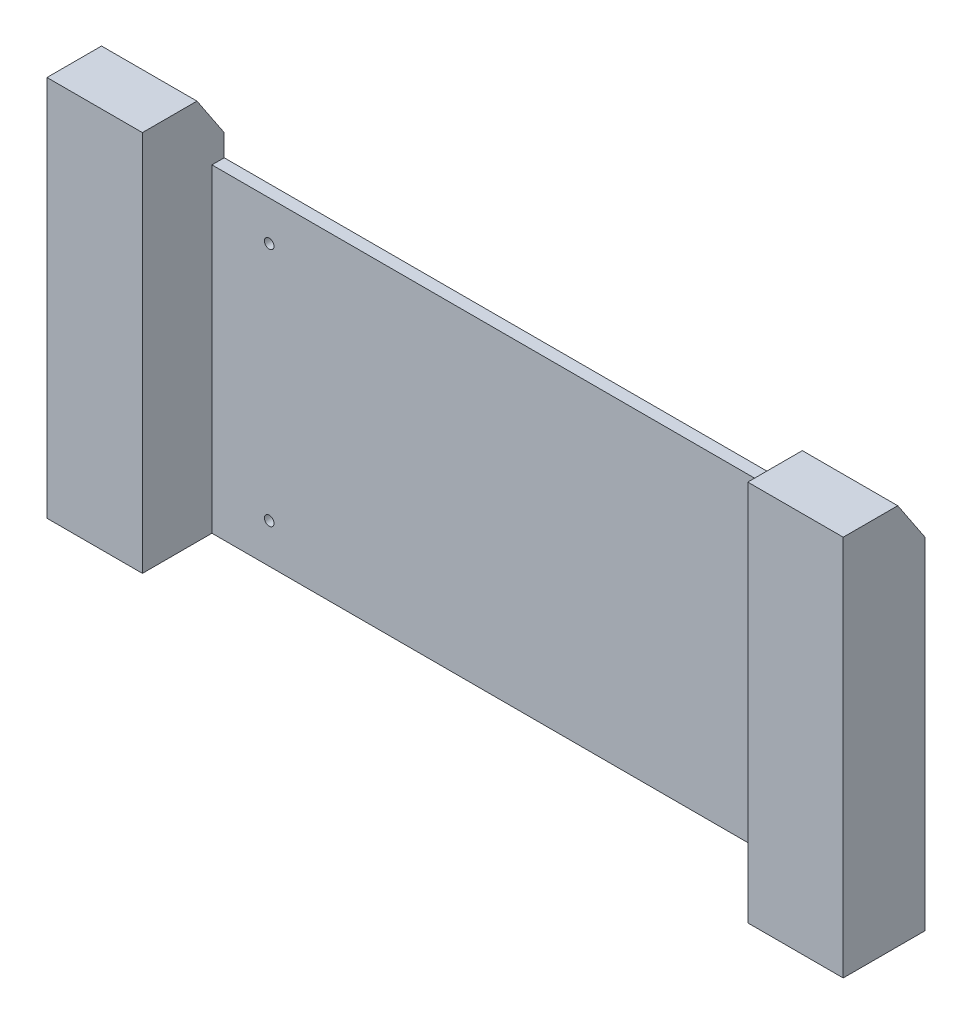
from build123d import *

# Parameters (mm, degrees)
SKETCH1_W               = 292
SKETCH1_H               = 117
BOSS_EXTRUDE1_DEPTH     = 4.5
CUT_EXTRUDE1_REACH      = 159.348
SKETCH1_3_R             = 1.75
MIRROR3_COPY_1_REACH    = 159.348
MIRROR3_COPY_1_SKETCH_R = 1.75
MIRROR3_COPY_2_REACH    = 159.348
MIRROR3_COPY_2_SKETCH_R = 1.75
SKETCH2_W               = 35
SKETCH2_H               = 140
BOSS_EXTRUDE2_DEPTH     = 30
CHAMFER1_SIZE           = 10
CHAMFER1_SIZE2          = 15
CHAMFER2_SIZE           = 15
CHAMFER2_SIZE2          = 10


with BuildPart() as part:
    # Sketch1 → Boss-Extrude1 (new body)
    with BuildSketch(Plane.XY):
        Rectangle(SKETCH1_W, SKETCH1_H)
    extrude(amount=BOSS_EXTRUDE1_DEPTH)

    # Sketch1_3 → Cut-Extrude1 (cut, up to next)
    with BuildSketch(Plane.XY, mode=Mode.PRIVATE) as cut_extrude1_sk1:
        with Locations((-90, 44)):
            Circle(SKETCH1_3_R)
    cut_extrude1_tool1 = extrude(cut_extrude1_sk1.sketch, amount=CUT_EXTRUDE1_REACH, mode=Mode.PRIVATE) & part.part
    cut_extrude1 = cut_extrude1_tool1.solids().sort_by_distance((-90, 44, 0))[0]
    add(cut_extrude1, mode=Mode.SUBTRACT)

    # Mirror2: Cut-Extrude1 across plane
    add(cut_extrude1.mirror(Plane.ZX), mode=Mode.SUBTRACT)

    # Mirror3 copy 1 sketch → Mirror3 copy 1 (cut, up to next)
    with BuildSketch(Plane(origin=(0, 0, 0), x_dir=(-1, 0, 0), z_dir=(0, 0, 1)), mode=Mode.PRIVATE) as mirror3_copy_1_sk1:
        with Locations((-90, 44)):
            Circle(MIRROR3_COPY_1_SKETCH_R)
    mirror3_copy_1_tool1 = extrude(mirror3_copy_1_sk1.sketch, amount=MIRROR3_COPY_1_REACH, mode=Mode.PRIVATE) & part.part
    add(mirror3_copy_1_tool1.solids().sort_by_distance((90, -44, 0))[0], mode=Mode.SUBTRACT)

    # Mirror3 copy 2 sketch → Mirror3 copy 2 (cut, up to next)
    with BuildSketch(Plane(origin=(0, 0, 0), x_dir=(-1, 0, 0), z_dir=(0, 0, 1)), mode=Mode.PRIVATE) as mirror3_copy_2_sk1:
        with Locations((-90, -44)):
            Circle(MIRROR3_COPY_2_SKETCH_R)
    mirror3_copy_2_tool1 = extrude(mirror3_copy_2_sk1.sketch, amount=MIRROR3_COPY_2_REACH, mode=Mode.PRIVATE) & part.part
    add(mirror3_copy_2_tool1.solids().sort_by_distance((90, 44, 0))[0], mode=Mode.SUBTRACT)

    # Sketch2 → Boss-Extrude2 (add)
    with BuildSketch(Plane(origin=(0, 0, 0), x_dir=(-1, 0, 0), z_dir=(0, 0, -1))):
        with Locations((-128.5, 11.5)):
            Rectangle(SKETCH2_W, SKETCH2_H)
    boss_extrude2 = extrude(amount=-BOSS_EXTRUDE2_DEPTH)

    # Chamfer1
    chamfer1_edges = [part.edges().sort_by_distance(p)[0] for p in [
        (128.5, 81.5, 0),
    ]]
    chamfer1_side = [part.faces().sort_by_distance(p)[0] for p in [
        (128.5, 81.5, 15),
    ]]
    chamfer(chamfer1_edges, length=CHAMFER1_SIZE, length2=CHAMFER1_SIZE2, reference=chamfer1_side[0])

    # Mirror5: Boss-Extrude2 across plane
    add(boss_extrude2.mirror(Plane(origin=(0, 0, 0), x_dir=(0, 0, 1), z_dir=(1, 0, 0))))

    # Chamfer2
    chamfer2_edges = [part.edges().sort_by_distance(p)[0] for p in [
        (-128.5, 81.5, 0),
    ]]
    chamfer2_side = [part.faces().sort_by_distance(p)[0] for p in [
        (-1.915975925, 2.0973848, 0),
    ]]
    chamfer(chamfer2_edges, length=CHAMFER2_SIZE, length2=CHAMFER2_SIZE2, reference=chamfer2_side[0])


solid = part.part
